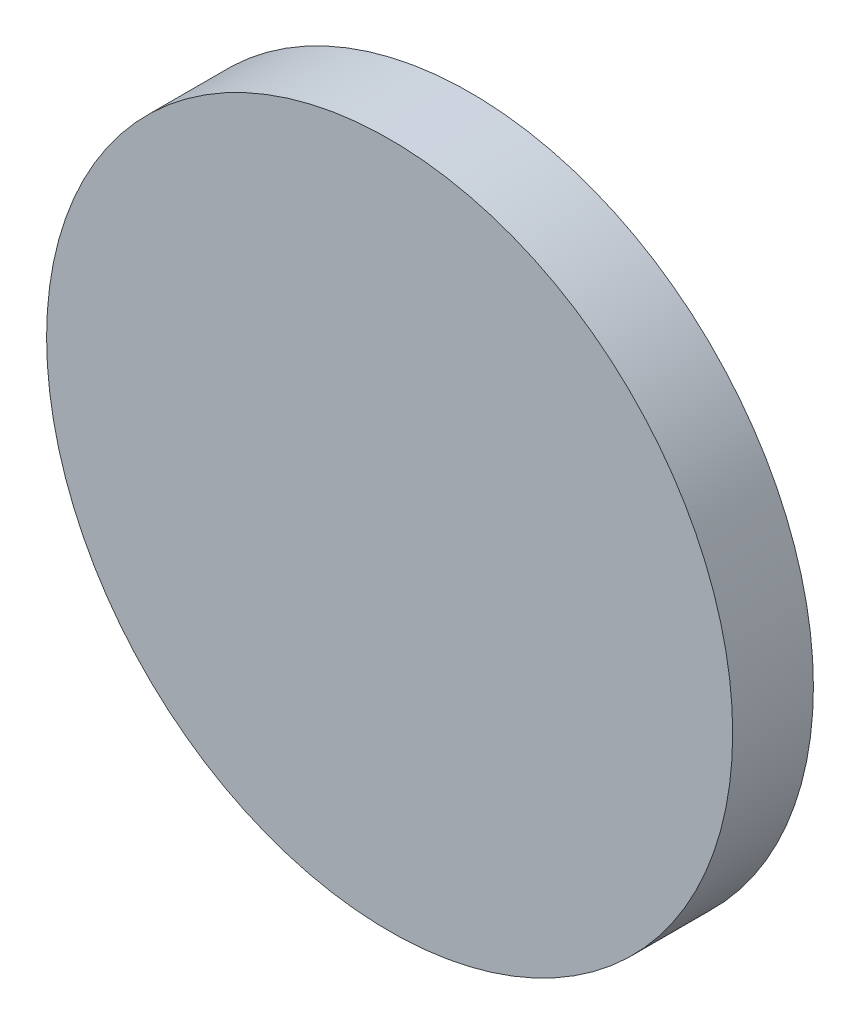
from build123d import *

# Parameters (mm, degrees)
SKETCH1_R           = 17
BOSS_EXTRUDE1_DEPTH = 4


with BuildPart() as part:
    # Sketch1 → Boss-Extrude1 (new body)
    with BuildSketch(Plane.XY):
        Circle(SKETCH1_R)
    extrude(amount=BOSS_EXTRUDE1_DEPTH)


solid = part.part
